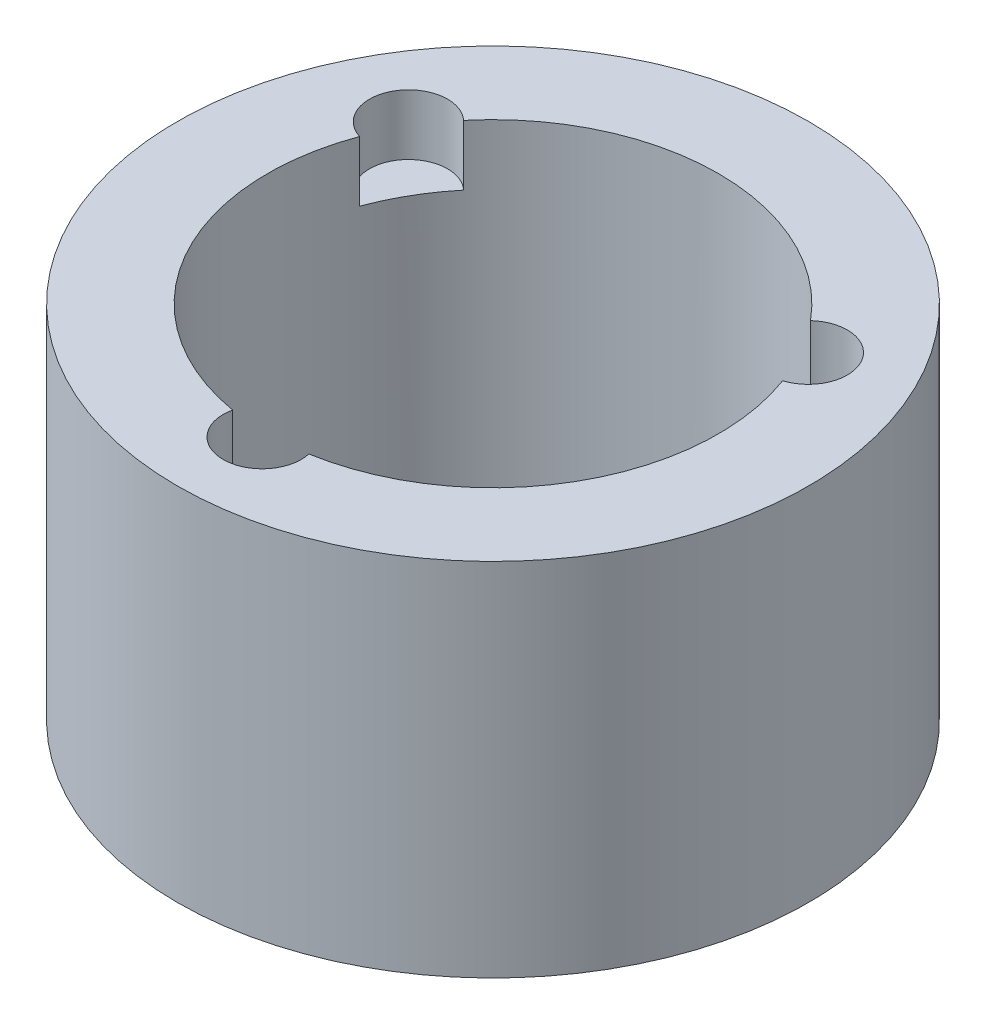
from build123d import *

# Parameters (mm, degrees)
SKETCH1_R           = 44.45
SKETCH1_R_2         = 31.75
BOSS_EXTRUDE1_DEPTH = 50.8
SKETCH3_R           = 5.5
CUT_EXTRUDE2_DEPTH  = 8.5


with BuildPart() as part:
    # Sketch1 → Boss-Extrude1 (new body)
    with BuildSketch(Plane(origin=(0, 0, 0), x_dir=(1, 0, 0), z_dir=(0, 1, 0))):
        Circle(SKETCH1_R)
        Circle(SKETCH1_R_2, mode=Mode.SUBTRACT)
    extrude(amount=BOSS_EXTRUDE1_DEPTH)

    # Sketch3 → Cut-Extrude2 (cut)
    with BuildSketch(Plane(origin=(0, 50.8, 0), x_dir=(1, 0, 0), z_dir=(0, 1, 0))):
        with Locations((-28.145825623, 16.25)):
            Circle(SKETCH3_R)
        with Locations((0, -32.5)):
            Circle(SKETCH3_R)
        with Locations((28.145825623, 16.25)):
            Circle(SKETCH3_R)
    extrude(amount=-CUT_EXTRUDE2_DEPTH, mode=Mode.SUBTRACT)


solid = part.part
